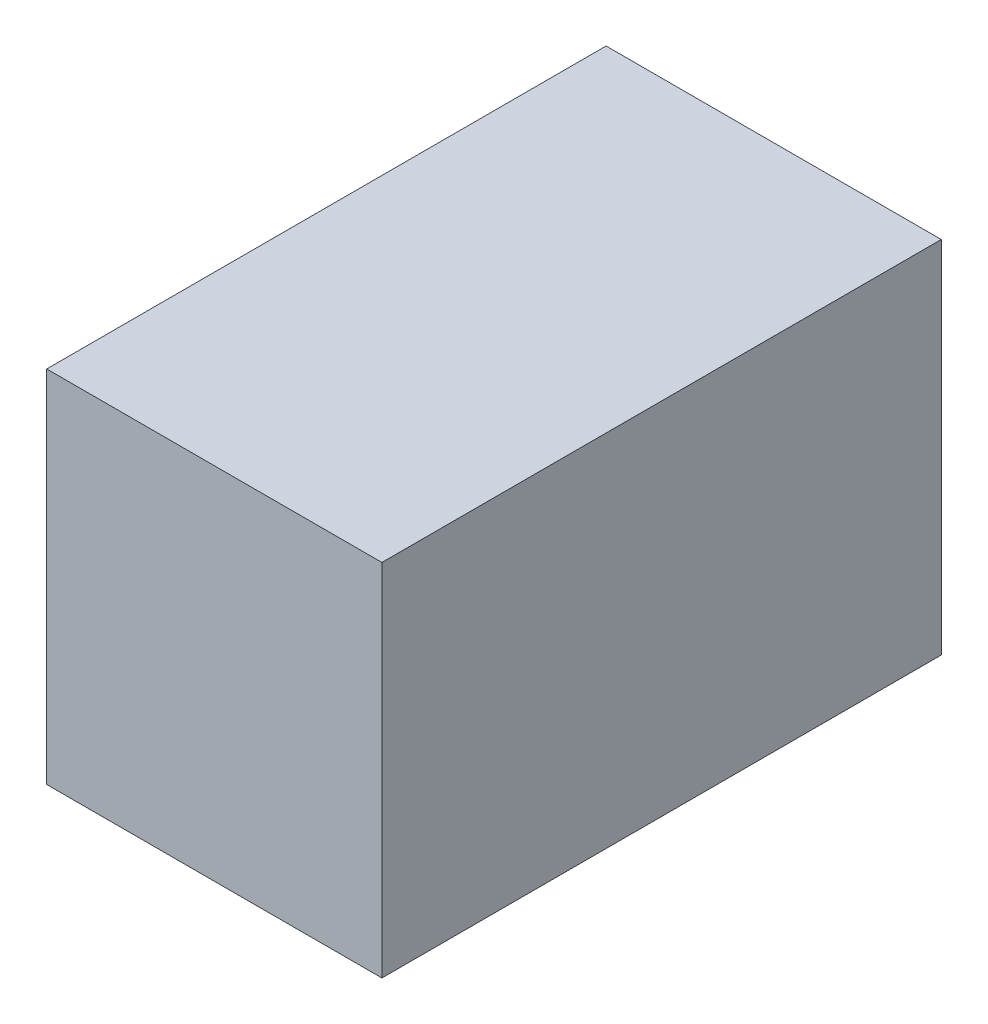
from build123d import *

# Parameters (mm, degrees)
SKETCH4_W           = 31.05
SKETCH4_H           = 18.55
BOSS_EXTRUDE1_DEPTH = 19
SHELL1_T            = 2
SKETCH5_W           = 12
SKETCH5_H           = 18.55
CUT_EXTRUDE1_DEPTH  = 2


with BuildPart() as part:
    # Sketch4 → Boss-Extrude1 (new body)
    with BuildSketch(Plane(origin=(0, 0, 0), x_dir=(0, 0, -1), z_dir=(1, 0, 0))):
        Rectangle(SKETCH4_W, SKETCH4_H)
    extrude(amount=BOSS_EXTRUDE1_DEPTH)

    # Shell1
    shell1_openings = [part.faces().sort_by_distance(p)[0] for p in [
        (0, 0, 0),
    ]]
    offset(amount=SHELL1_T, openings=shell1_openings, kind=Kind.INTERSECTION)

    # Sketch5 → Cut-Extrude1 (cut)
    with BuildSketch(Plane(origin=(0, 0, -17.525), x_dir=(-1, 0, 0), z_dir=(0, 0, -1))):
        with Locations((-6, 0)):
            Rectangle(SKETCH5_W, SKETCH5_H)
    extrude(amount=-CUT_EXTRUDE1_DEPTH, mode=Mode.SUBTRACT)


solid = part.part
